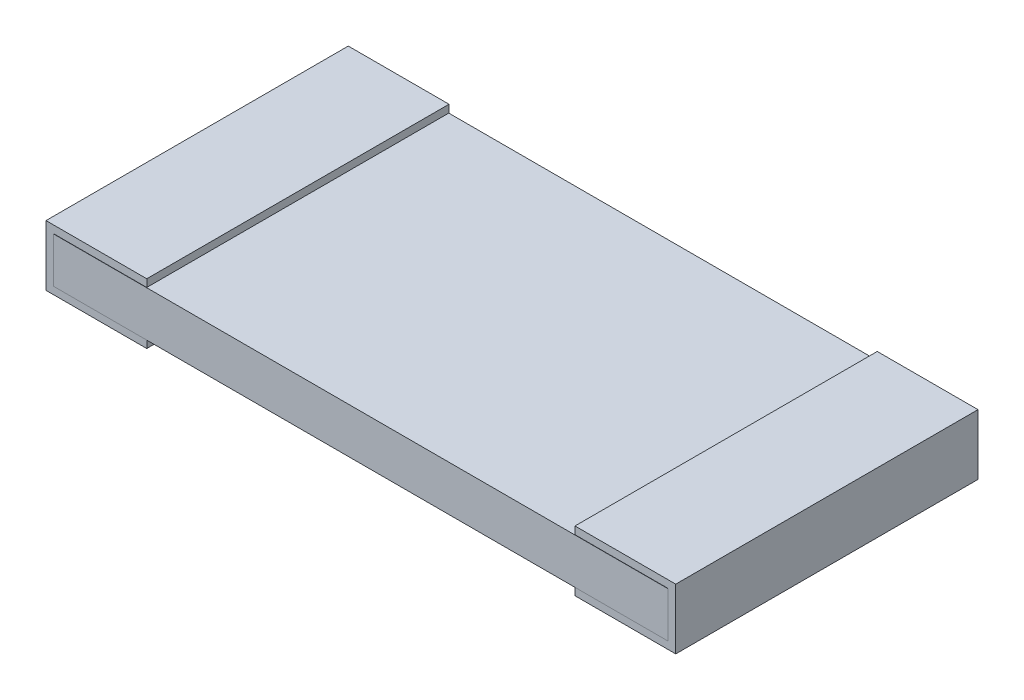
from build123d import *

# Parameters (mm, degrees)
SKETCH1_W           = 6.1976
SKETCH1_H           = 0.4572
BASE_EXTRUDE_DEPTH  = 1.524
BOSS_EXTRUDE1_DEPTH = 3.048


with BuildPart() as part:
    # Sketch1 → Base-Extrude (new body, symmetric)
    with BuildSketch(Plane.XY):
        with Locations((3.175, 0.3048)):
            Rectangle(SKETCH1_W, SKETCH1_H)
    extrude(amount=BASE_EXTRUDE_DEPTH, both=True)

    # Sketch2 → Boss-Extrude1 (add)
    with BuildSketch(Plane(origin=(0, 0, -1.52654), x_dir=(-1, 0, 0), z_dir=(0, 0, -1))):
        Polygon((0, 0), (-1.016, 0), (-1.016, 0.0762), (-0.0762, 0.0762), (-0.0762, 0.5334), (-1.016, 0.5334), (-1.016, 0.6096), (0, 0.6096), align=None)
    boss_extrude1 = extrude(amount=-BOSS_EXTRUDE1_DEPTH)

    # Mirror1: Boss-Extrude1 across plane
    add(boss_extrude1.mirror(Plane(origin=(3.175, 0, 0), x_dir=(0, 0, 1), z_dir=(1, 0, 0))))


solid = part.part
